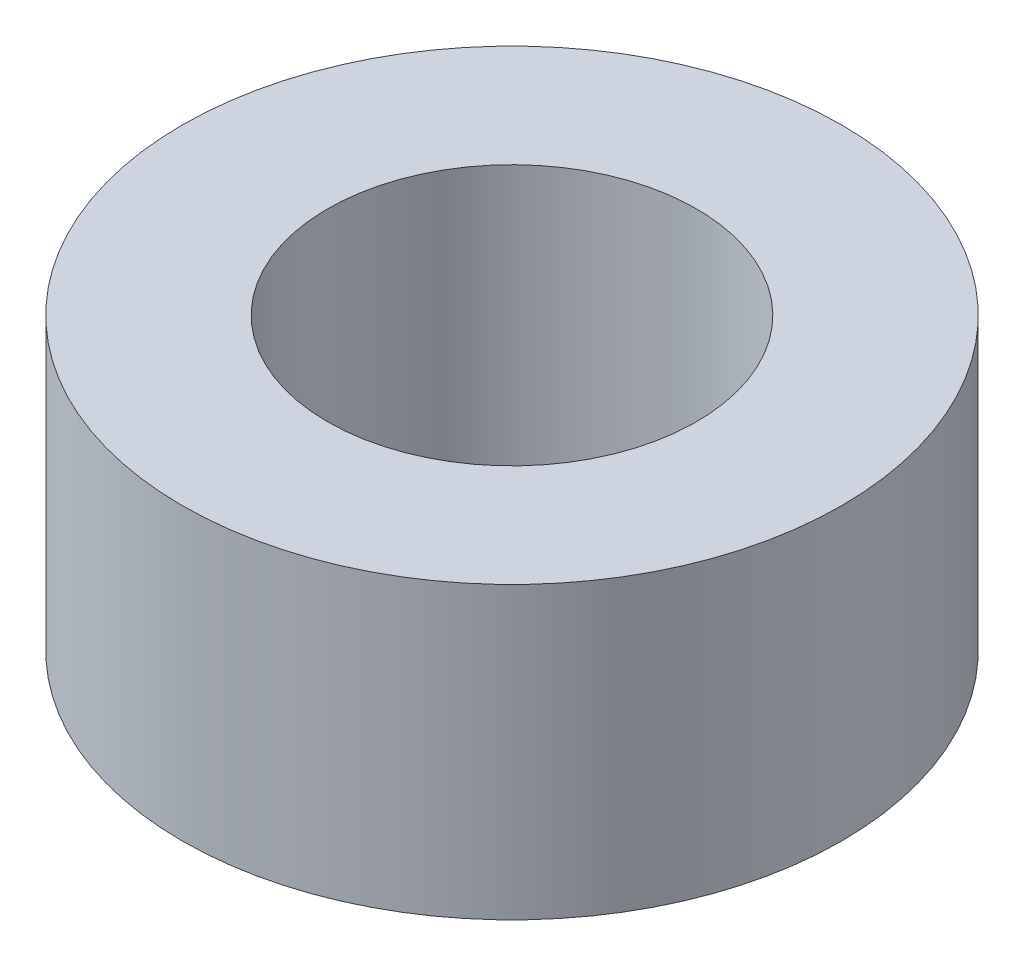
from build123d import *

# Parameters (mm, degrees)
SKETCH1_R           = 11.35
SKETCH1_R_2         = 6.35
BOSS_EXTRUDE1_DEPTH = 10


with BuildPart() as part:
    # Sketch1 → Boss-Extrude1 (new body)
    with BuildSketch(Plane(origin=(0, 0, 0), x_dir=(1, 0, 0), z_dir=(0, 1, 0))):
        Circle(SKETCH1_R)
        Circle(SKETCH1_R_2, mode=Mode.SUBTRACT)
    extrude(amount=BOSS_EXTRUDE1_DEPTH)


solid = part.part
